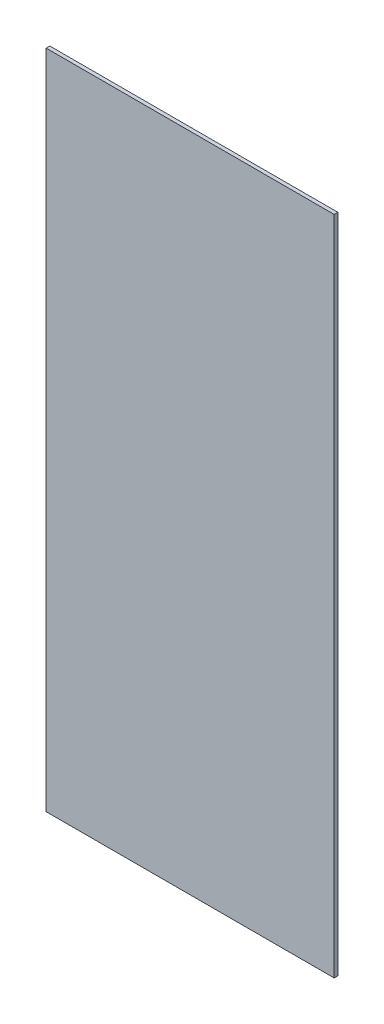
from build123d import *

# Parameters (mm, degrees)
SKETCH1_W           = 248.92
SKETCH1_H           = 571.5
BOSS_EXTRUDE1_DEPTH = 3.175


with BuildPart() as part:
    # Sketch1 → Boss-Extrude1 (new body)
    with BuildSketch(Plane.XY):
        with Locations((124.46, 285.75)):
            Rectangle(SKETCH1_W, SKETCH1_H)
    extrude(amount=BOSS_EXTRUDE1_DEPTH)


solid = part.part
